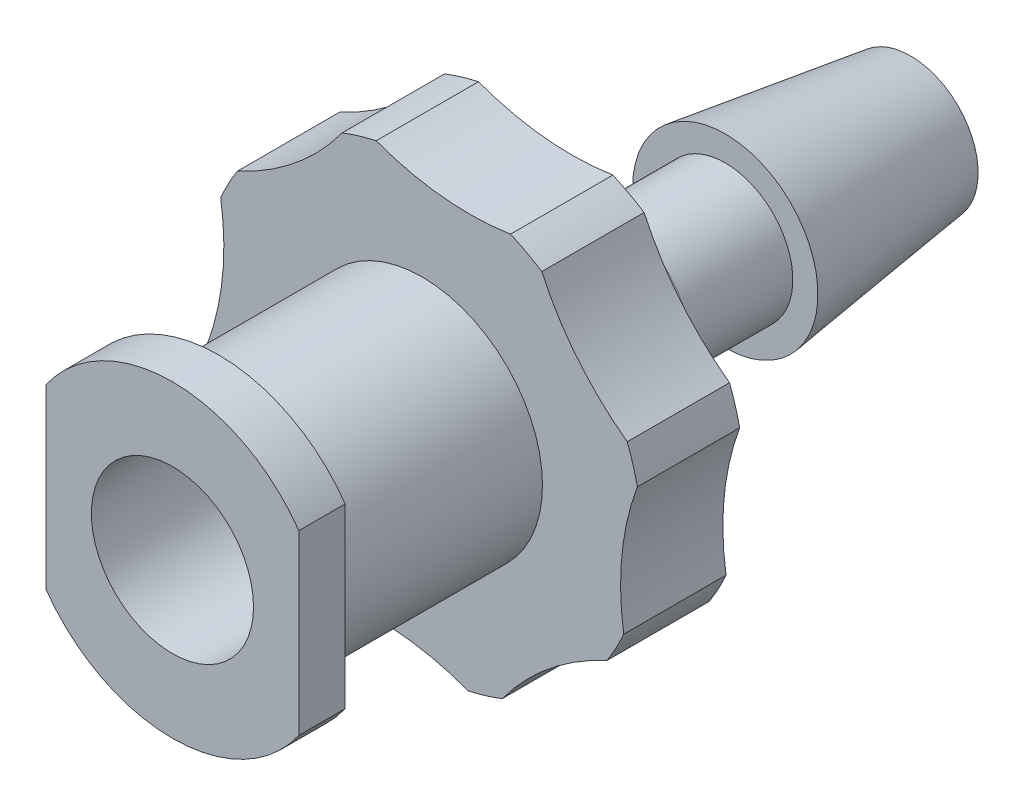
from build123d import *

# Parameters (mm, degrees)
BOSS_EXTRUDE1_DEPTH                                 = 1.2
SKETCH2_R                                           = 3.115
BOSS_EXTRUDE2_DEPTH                                 = 5.27
SKETCH3_R                                           = 5.7
BOSS_EXTRUDE3_DEPTH                                 = 2.65
CUT_EXTRUDE1_DEPTH                                  = 3.65
CUT_EXTRUDE2_DEPTH                                  = 3.65
CUT_EXTRUDE3_DEPTH                                  = 3.65
CUT_EXTRUDE4_DEPTH                                  = 3.65
CUT_EXTRUDE5_DEPTH                                  = 3.65
CUT_EXTRUDE6_DEPTH                                  = 3.65
CUT_EXTRUDE7_DEPTH                                  = 3.65
CUT_EXTRUDE8_DEPTH                                  = 3.65
CBORE_FOR_2_BINDING_HEAD_MACHINE_SCREW1_D           = 2.43
CBORE_FOR_2_BINDING_HEAD_MACHINE_SCREW1_DEPTH       = 19.12
CBORE_FOR_2_BINDING_HEAD_MACHINE_SCREW1_CBORE_D     = 4.2
CBORE_FOR_2_BINDING_HEAD_MACHINE_SCREW1_CBORE_DEPTH = 7.5
CHAMFER1_SIZE                                       = 0.6
CHAMFER1_SIZE2                                      = 2.5
SCALE1_SCALE                                        = 0.65


with BuildPart() as part:
    # Sketch1 → Boss-Extrude1 (new body)
    with BuildSketch(Plane.XY.offset(19.12)):
        with BuildLine():
            Line((-3.275, 2.296600749), (-3.275, -2.296600749))
            ThreePointArc((-3.275, -2.296600749), (0, -4), (3.275, -2.296600749))
            Line((3.275, -2.296600749), (3.275, 2.296600749))
            ThreePointArc((3.275, 2.296600749), (0, 4), (-3.275, 2.296600749))
        make_face()
    extrude(amount=-BOSS_EXTRUDE1_DEPTH)

    # Sketch2 → Boss-Extrude2 (add)
    with BuildSketch(Plane(origin=(0, 0, 17.92), x_dir=(-1, 0, 0), z_dir=(0, 0, -1))):
        Circle(SKETCH2_R)
    extrude(amount=BOSS_EXTRUDE2_DEPTH)

    # Sketch3 → Boss-Extrude3 (add)
    with BuildSketch(Plane.XY.offset(12.65)):
        Circle(SKETCH3_R)
    extrude(amount=-BOSS_EXTRUDE3_DEPTH)

    # Sketch4 → Cut-Extrude1 (cut, through all)
    with BuildSketch(Plane.XY.offset(12.65)):
        with BuildLine():
            ThreePointArc((-5.220198487, 2.289001477), (-5.670846635, 0.575759012), (-5.573734722, -1.193097334))
            ThreePointArc((-5.573734722, -1.193097334), (-5.173403948, 0.525253836), (-5.220198487, 2.289001477))
        make_face()
    extrude(amount=-CUT_EXTRUDE1_DEPTH, mode=Mode.SUBTRACT)

    # Sketch5 → Cut-Extrude2 (cut, through all)
    with BuildSketch(Plane.XY.offset(12.65)):
        with BuildLine():
            ThreePointArc((-2.072669282, 5.309806215), (-3.602771009, 4.417017213), (-4.784872834, 3.097578403))
            ThreePointArc((-4.784872834, 3.097578403), (-3.286738464, 4.029559562), (-2.072669282, 5.309806215))
        make_face()
    extrude(amount=-CUT_EXTRUDE2_DEPTH, mode=Mode.SUBTRACT)

    # Sketch6 → Cut-Extrude3 (cut, through all)
    with BuildSketch(Plane.XY.offset(12.65)):
        with BuildLine():
            ThreePointArc((2.289001477, 5.220198487), (0.575759012, 5.670846635), (-1.193097334, 5.573734722))
            ThreePointArc((-1.193097334, 5.573734722), (0.525253836, 5.173403948), (2.289001477, 5.220198487))
        make_face()
    extrude(amount=-CUT_EXTRUDE3_DEPTH, mode=Mode.SUBTRACT)

    # Sketch7 → Cut-Extrude4 (cut, through all)
    with BuildSketch(Plane.XY.offset(12.65)):
        with BuildLine():
            ThreePointArc((5.309806215, 2.072669282), (4.417017213, 3.602771009), (3.097578403, 4.784872834))
            ThreePointArc((3.097578403, 4.784872834), (4.029559562, 3.286738464), (5.309806215, 2.072669282))
        make_face()
    extrude(amount=-CUT_EXTRUDE4_DEPTH, mode=Mode.SUBTRACT)

    # Sketch8 → Cut-Extrude5 (cut, through all)
    with BuildSketch(Plane.XY.offset(12.65)):
        with BuildLine():
            ThreePointArc((5.220198487, -2.289001477), (5.670846635, -0.575759012), (5.573734722, 1.193097334))
            ThreePointArc((5.573734722, 1.193097334), (5.173403948, -0.525253836), (5.220198487, -2.289001477))
        make_face()
    extrude(amount=-CUT_EXTRUDE5_DEPTH, mode=Mode.SUBTRACT)

    # Sketch9 → Cut-Extrude6 (cut, through all)
    with BuildSketch(Plane.XY.offset(12.65)):
        with BuildLine():
            ThreePointArc((2.072669282, -5.309806215), (3.602771009, -4.417017213), (4.784872834, -3.097578403))
            ThreePointArc((4.784872834, -3.097578403), (3.286738464, -4.029559562), (2.072669282, -5.309806215))
        make_face()
    extrude(amount=-CUT_EXTRUDE6_DEPTH, mode=Mode.SUBTRACT)

    # Sketch10 → Cut-Extrude7 (cut, through all)
    with BuildSketch(Plane.XY.offset(12.65)):
        with BuildLine():
            ThreePointArc((-2.289001477, -5.220198487), (-0.575759012, -5.670846635), (1.193097334, -5.573734722))
            ThreePointArc((1.193097334, -5.573734722), (-0.525253836, -5.173403948), (-2.289001477, -5.220198487))
        make_face()
    extrude(amount=-CUT_EXTRUDE7_DEPTH, mode=Mode.SUBTRACT)

    # Sketch11 → Cut-Extrude8 (cut, through all)
    with BuildSketch(Plane.XY.offset(12.65)):
        with BuildLine():
            ThreePointArc((-5.309806215, -2.072669282), (-4.417017213, -3.602771009), (-3.097578403, -4.784872834))
            ThreePointArc((-3.097578403, -4.784872834), (-4.029559562, -3.286738464), (-5.309806215, -2.072669282))
        make_face()
    extrude(amount=-CUT_EXTRUDE8_DEPTH, mode=Mode.SUBTRACT)

    # Sketch12 → Revolve1 (revolve)
    with BuildSketch(Plane.XZ):
        Polygon((1.75, 10), (0, 10), (0, 0), (1.75, 0), (2.4, 4.8), (1.75, 4.8), align=None)
    revolve(axis=Axis((0, 0, 10), (0, 0, -1)))

    # CBORE for #2 Binding Head Machine Screw1
    with Locations(Plane.XY.offset(19.12)):
        with Locations((0, 0)):
            CounterBoreHole(CBORE_FOR_2_BINDING_HEAD_MACHINE_SCREW1_D / 2, CBORE_FOR_2_BINDING_HEAD_MACHINE_SCREW1_CBORE_D / 2, CBORE_FOR_2_BINDING_HEAD_MACHINE_SCREW1_CBORE_DEPTH, depth=CBORE_FOR_2_BINDING_HEAD_MACHINE_SCREW1_DEPTH)

    # Chamfer1
    chamfer1_edges = [part.edges().sort_by_distance(p)[0] for p in [
        (-1.75, 0, 10),
    ]]
    chamfer1_side = [part.faces().sort_by_distance(p)[0] for p in [
        (-5.016561239, 0.509329652, 10),
    ]]
    chamfer(chamfer1_edges, length=CHAMFER1_SIZE, length2=CHAMFER1_SIZE2, reference=chamfer1_side[0])


with BuildPart() as part_1:
    # Scale1: scaled about (0, 0, 11.614719244)
    add(part.part.scale(SCALE1_SCALE).moved(Location((0, 0, 4.065151735))))


solid = part_1.part
